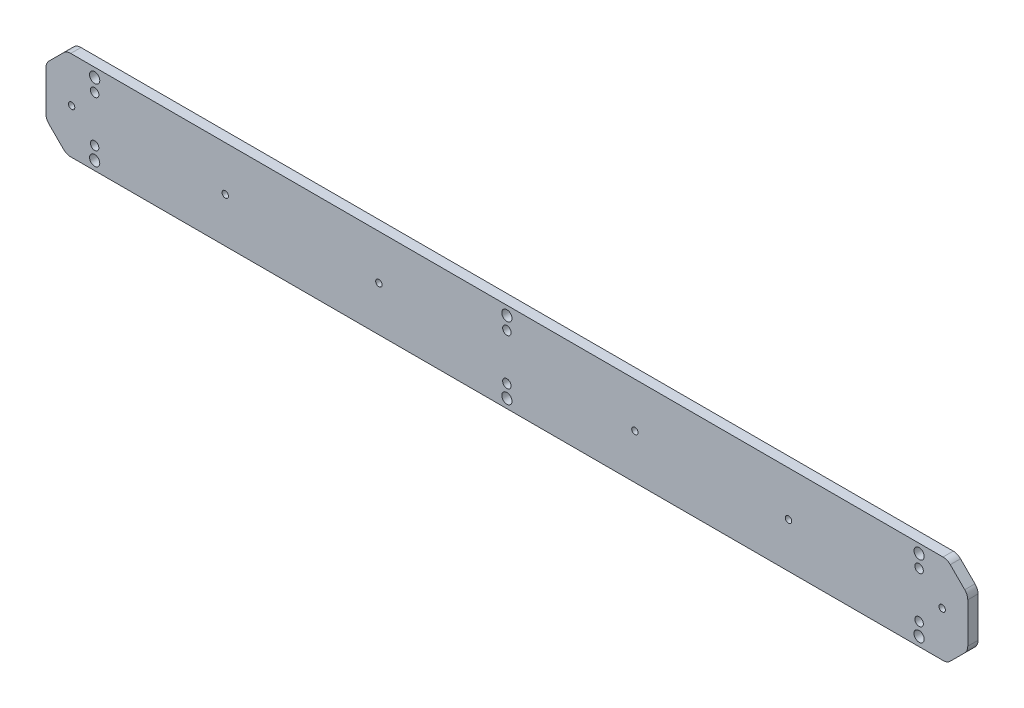
from build123d import *

# Parameters (mm, degrees)
CROQUIS1_W                                 = 360
CROQUIS1_H                                 = 35
SALIENTE_EXTRUIR1_DEPTH                    = 4
CROQUIS2_R                                 = 2
CORTAR_EXTRUIR1_DEPTH                      = 5
PERFORADOR_PARA_ROSCAR_PARA_MACHO_DE_ROS_D = 3.3
TALADRO_ROSCADO_M31_D                      = 2.5
CHAFL_N1_SIZE                              = 8
REDONDEO2_R                                = 4


with BuildPart() as part:
    # Croquis1 → Saliente-Extruir1 (new body)
    with BuildSketch(Plane.XY):
        Rectangle(CROQUIS1_W, CROQUIS1_H)
    extrude(amount=SALIENTE_EXTRUIR1_DEPTH)

    # Croquis2 → Cortar-Extruir1 (cut)
    with BuildSketch(Plane.XY.offset(4)):
        with Locations((0, 14)):
            Circle(CROQUIS2_R)
        with Locations((0, -14)):
            Circle(CROQUIS2_R)
        with Locations((161, 14)):
            Circle(CROQUIS2_R)
        with Locations((161, -14)):
            Circle(CROQUIS2_R)
        with Locations((-161, 14)):
            Circle(CROQUIS2_R)
        with Locations((-161, -14)):
            Circle(CROQUIS2_R)
    extrude(amount=-CORTAR_EXTRUIR1_DEPTH, mode=Mode.SUBTRACT)

    # Perforador para roscar para macho de roscar para M41 (through all)
    with Locations(Plane(origin=(-161, 9, 4), x_dir=(1, 0, 0), z_dir=(0, 0, 1))):
        with Locations((0, 0), (0, -18), (161, 0), (161, -18), (322, 0), (322, -18)):
            Hole(PERFORADOR_PARA_ROSCAR_PARA_MACHO_DE_ROS_D / 2)

    # Taladro roscado M31 (through all)
    with Locations(Plane.XY.offset(4)):
        with Locations((-170, 0), (-110, 0), (-50, 0), (50, 0), (110, 0), (170, 0)):
            Hole(TALADRO_ROSCADO_M31_D / 2)

    # Chaflán1
    chafl_n1_edges = [part.edges().sort_by_distance(p)[0] for p in [
        (180, -17.5, 2),
        (-180, -17.5, 2),
        (-180, 17.5, 2),
        (180, 17.5, 2),
    ]]
    chamfer(chafl_n1_edges, length=CHAFL_N1_SIZE)

    # Redondeo2
    redondeo2_edges = [part.edges().sort_by_distance(p)[0] for p in [
        (180, 9.5, 2),
        (180, -9.5, 2),
        (-172, -17.5, 2),
        (172, -17.5, 2),
        (-172, 17.5, 2),
        (172, 17.5, 2),
        (-180, 9.5, 2),
        (-180, -9.5, 2),
    ]]
    fillet(redondeo2_edges, radius=REDONDEO2_R)


solid = part.part
